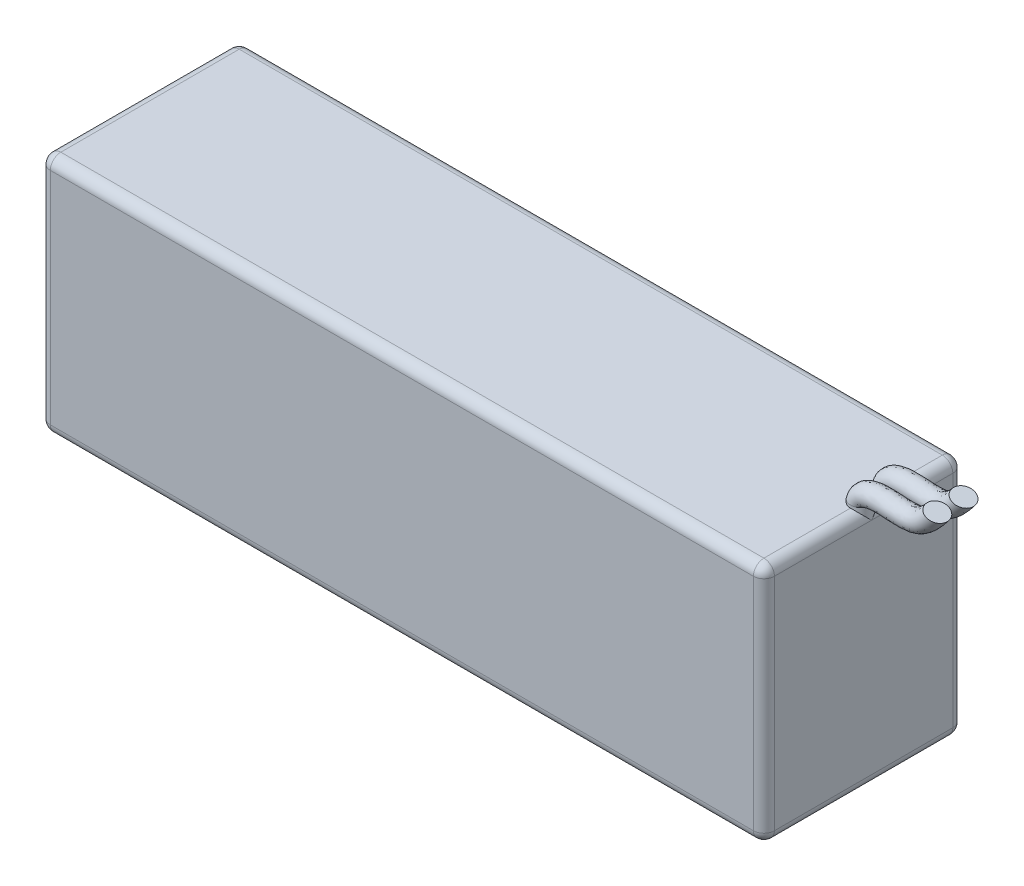
from build123d import *

# Parameters (mm, degrees)
SZKIC1_W                         = 138
SZKIC1_H                         = 38
DODANIE_WYCI_GNI_CIE1_DEPTH      = 46
ZAOKR_GLENIE1_R                  = 2
DODANIE_WYCI_GNI_CIE2_REACH      = 87.348
DODANIE_WYCI_GNI_CIE2_END_RADIUS = 2
SZKIC3_R                         = 2
SZKIC5_R                         = 2


with BuildPart() as part:
    # Szkic1 → Dodanie-wyciągnięcie1 (new body)
    with BuildSketch(Plane(origin=(0, 0, 0), x_dir=(1, 0, 0), z_dir=(0, 1, 0))):
        Rectangle(SZKIC1_W, SZKIC1_H)
    extrude(amount=DODANIE_WYCI_GNI_CIE1_DEPTH)

    # Zaokrąglenie1
    zaokr_glenie1_edges = [part.edges().sort_by_distance(p)[0] for p in [
        (-69, 46, 0),
        (0, 46, 19),
        (69, 46, 0),
        (0, 0, 19),
        (-69, 0, 0),
        (0, 0, -19),
        (69, 0, 0),
        (69, 23, 19),
        (-69, 23, 19),
        (-69, 23, -19),
        (69, 23, -19),
        (0, 46, -19),
    ]]
    fillet(zaokr_glenie1_edges, radius=ZAOKR_GLENIE1_R)

    # Dodanie-wyciągnięcie2: up to this cylinder (the profile starts outside it)
    dodanie_wyci_gni_cie2_end = Plane(origin=(67, 44, -4), z_dir=(0, 0, -1)) * Cylinder(DODANIE_WYCI_GNI_CIE2_END_RADIUS, 184.696, mode=Mode.PRIVATE)
    # Szkic3 → Dodanie-wyciągnięcie2 (add, up to the surface)
    with BuildSketch(Plane(origin=(0, 46.5, 0), x_dir=(1, 0, 0), z_dir=(0, 1, 0)), mode=Mode.PRIVATE) as dodanie_wyci_gni_cie2_sk1:
        with Locations(Location((67, 6.5, 0), (0, 0, 270))):
            Circle(SZKIC3_R)
    dodanie_wyci_gni_cie2_tool1 = extrude(dodanie_wyci_gni_cie2_sk1.sketch, amount=-DODANIE_WYCI_GNI_CIE2_REACH, mode=Mode.PRIVATE) - dodanie_wyci_gni_cie2_end
    add(dodanie_wyci_gni_cie2_tool1.solids().sort_by_distance((67, 46.5, -6.5))[0])
    # Szkic3 → Dodanie-wyciągnięcie2 (add, up to the surface)
    with BuildSketch(Plane(origin=(0, 46.5, 0), x_dir=(1, 0, 0), z_dir=(0, 1, 0)), mode=Mode.PRIVATE) as dodanie_wyci_gni_cie2_sk2:
        with Locations(Location((67, 1.5, 0), (0, 0, 270))):
            Circle(SZKIC3_R)
    dodanie_wyci_gni_cie2_tool2 = extrude(dodanie_wyci_gni_cie2_sk2.sketch, amount=-DODANIE_WYCI_GNI_CIE2_REACH, mode=Mode.PRIVATE) - dodanie_wyci_gni_cie2_end
    add(dodanie_wyci_gni_cie2_tool2.solids().sort_by_distance((67, 46.5, -1.5))[0])

    # Wyciągnięcie po ścieżce1: sweep along a path in Szkic4
    with BuildLine() as wyci_gni_cie_po_cie_ce1_path:  # in the path sketch's own coordinates; laid on its plane below (add() does not lay a ready-made edge on the line's plane)
        add(Edge.make_bspline(
            [(-67, 46.5), (-67.812300982, 48.700029071), (-76.558056505, 48.053598024), (-78.81196866, 48.196334496), (-81.546543778, 51.620091174)],
            knots=[0, 0, 0, 0, 0.368299585, 1, 1, 1, 1], degree=3))
    # Szkic5 → Wyciągnięcie po ścieżce1 (sweep)
    with BuildSketch(Plane(origin=(0, 46.5, 0), x_dir=(1, 0, 0), z_dir=(0, 1, 0))):
        with Locations((67, 6.5)):
            Circle(SZKIC5_R)
        with Locations((67, 1.5)):
            Circle(SZKIC5_R)
    sweep(path=Plane(origin=(0, 0, -4), x_dir=(-1, 0, 0), z_dir=(0, 0, -1)) * wyci_gni_cie_po_cie_ce1_path.line)


solid = part.part
